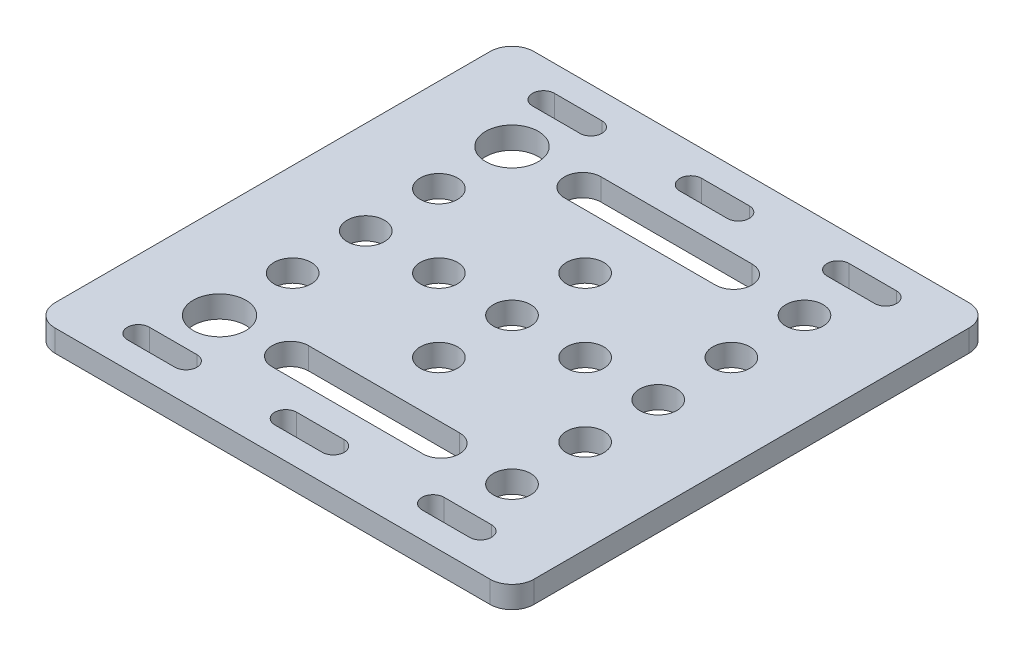
from build123d import *

# Parameters (mm, degrees)
SKETCH1_W           = 65.5
SKETCH1_H           = 65.5
BOSS_EXTRUDE1_DEPTH = 3
SKETCH2_R           = 3.6
SKETCH2_R_2         = 2.55
CUT_EXTRUDE1_DEPTH  = 4
FILLET1_R           = 3


with BuildPart() as part:
    # Sketch1 → Boss-Extrude1 (new body)
    with BuildSketch(Plane(origin=(0, 0, 0), x_dir=(1, 0, 0), z_dir=(0, 1, 0))):
        Rectangle(SKETCH1_W, SKETCH1_H)
    extrude(amount=BOSS_EXTRUDE1_DEPTH)

    # Sketch2 → Cut-Extrude1 (cut, through all)
    with BuildSketch(Plane(origin=(0, 3, 0), x_dir=(1, 0, 0), z_dir=(0, 1, 0))):
        with BuildLine():
            ThreePointArc((-23.4, 29.2), (-24.9, 27.7), (-23.4, 26.2))
            Line((-23.4, 26.2), (-23.4, 29.2))
        make_face()
        with BuildLine():
            Line((-23.4, 29.2), (-23.4, 26.2))
            ThreePointArc((-23.4, 26.2), (-22.339339828, 26.639339828), (-21.9, 27.7))
            ThreePointArc((-21.9, 27.7), (-22.339339828, 28.760660172), (-23.4, 29.2))
        make_face()
        with BuildLine():
            Line((-23.4, 26.2), (-16.9, 26.2))
            ThreePointArc((-16.9, 26.2), (-18.4, 27.7), (-16.9, 29.2))
            Line((-16.9, 29.2), (-23.4, 29.2))
            ThreePointArc((-23.4, 29.2), (-22.339339828, 28.760660172), (-21.9, 27.7))
            ThreePointArc((-21.9, 27.7), (-22.339339828, 26.639339828), (-23.4, 26.2))
        make_face()
        with BuildLine():
            ThreePointArc((-16.9, 29.2), (-18.4, 27.7), (-16.9, 26.2))
            Line((-16.9, 26.2), (-16.9, 29.2))
        make_face()
        with BuildLine():
            Line((-16.9, 29.2), (-16.9, 26.2))
            ThreePointArc((-16.9, 26.2), (-15.839339828, 26.639339828), (-15.4, 27.7))
            ThreePointArc((-15.4, 27.7), (-15.839339828, 28.760660172), (-16.9, 29.2))
        make_face()
        with BuildLine():
            ThreePointArc((-1.75, 27.7), (-2.189339828, 28.760660172), (-3.25, 29.2))
            Line((-3.25, 29.2), (-3.25, 26.2))
            ThreePointArc((-3.25, 26.2), (-2.189339828, 26.639339828), (-1.75, 27.7))
        make_face()
        with BuildLine():
            Line((-3.25, 26.2), (-3.25, 29.2))
            ThreePointArc((-3.25, 29.2), (-4.75, 27.7), (-3.25, 26.2))
        make_face()
        with BuildLine():
            ThreePointArc((3.25, 26.2), (1.75, 27.7), (3.25, 29.2))
            Line((3.25, 29.2), (-3.25, 29.2))
            ThreePointArc((-3.25, 29.2), (-2.189339828, 28.760660172), (-1.75, 27.7))
            ThreePointArc((-1.75, 27.7), (-2.189339828, 26.639339828), (-3.25, 26.2))
            Line((-3.25, 26.2), (3.25, 26.2))
        make_face()
        with BuildLine():
            ThreePointArc((4.75, 27.7), (4.310660172, 28.760660172), (3.25, 29.2))
            Line((3.25, 29.2), (3.25, 26.2))
            ThreePointArc((3.25, 26.2), (4.310660172, 26.639339828), (4.75, 27.7))
        make_face()
        with BuildLine():
            Line((3.25, 26.2), (3.25, 29.2))
            ThreePointArc((3.25, 29.2), (1.75, 27.7), (3.25, 26.2))
        make_face()
        with BuildLine():
            ThreePointArc((18.4, 27.7), (17.960660172, 28.760660172), (16.9, 29.2))
            Line((16.9, 29.2), (16.9, 26.2))
            ThreePointArc((16.9, 26.2), (17.960660172, 26.639339828), (18.4, 27.7))
        make_face()
        with BuildLine():
            Line((16.9, 26.2), (16.9, 29.2))
            ThreePointArc((16.9, 29.2), (15.4, 27.7), (16.9, 26.2))
        make_face()
        with BuildLine():
            ThreePointArc((23.4, 26.2), (21.9, 27.7), (23.4, 29.2))
            Line((23.4, 29.2), (16.9, 29.2))
            ThreePointArc((16.9, 29.2), (17.960660172, 28.760660172), (18.4, 27.7))
            ThreePointArc((18.4, 27.7), (17.960660172, 26.639339828), (16.9, 26.2))
            Line((16.9, 26.2), (23.4, 26.2))
        make_face()
        with BuildLine():
            ThreePointArc((24.9, 27.7), (24.460660172, 28.760660172), (23.4, 29.2))
            Line((23.4, 29.2), (23.4, 26.2))
            ThreePointArc((23.4, 26.2), (24.460660172, 26.639339828), (24.9, 27.7))
        make_face()
        with BuildLine():
            Line((23.4, 26.2), (23.4, 29.2))
            ThreePointArc((23.4, 29.2), (21.9, 27.7), (23.4, 26.2))
        make_face()
        with Locations((-20, 20)):
            Circle(SKETCH2_R)
        with BuildLine():
            ThreePointArc((-10.32, 22.5), (-12.82, 20), (-10.32, 17.5))
            Line((-10.32, 17.5), (-10.32, 22.5))
        make_face()
        with BuildLine():
            Line((-10.32, 22.5), (-10.32, 17.5))
            ThreePointArc((-10.32, 17.5), (-8.552233047, 18.232233047), (-7.82, 20))
            ThreePointArc((-7.82, 20), (-8.552233047, 21.767766953), (-10.32, 22.5))
        make_face()
        with BuildLine():
            Line((-10.32, 17.5), (10.32, 17.5))
            ThreePointArc((10.32, 17.5), (7.82, 20), (10.32, 22.5))
            Line((10.32, 22.5), (-10.32, 22.5))
            ThreePointArc((-10.32, 22.5), (-8.552233047, 21.767766953), (-7.82, 20))
            ThreePointArc((-7.82, 20), (-8.552233047, 18.232233047), (-10.32, 17.5))
        make_face()
        with BuildLine():
            ThreePointArc((10.32, 22.5), (7.82, 20), (10.32, 17.5))
            Line((10.32, 17.5), (10.32, 22.5))
        make_face()
        with BuildLine():
            Line((10.32, 22.5), (10.32, 17.5))
            ThreePointArc((10.32, 17.5), (12.087766953, 18.232233047), (12.82, 20))
            ThreePointArc((12.82, 20), (12.087766953, 21.767766953), (10.32, 22.5))
        make_face()
        with Locations((20, 20)):
            Circle(SKETCH2_R_2)
        with Locations((-20, 10)):
            Circle(SKETCH2_R_2)
        with Locations((0, 10)):
            Circle(SKETCH2_R_2)
        with Locations((20, 10)):
            Circle(SKETCH2_R_2)
        with Locations((-20, 0)):
            Circle(SKETCH2_R_2)
        with Locations((-10, 0)):
            Circle(SKETCH2_R_2)
        Circle(SKETCH2_R_2)
        with Locations((10, 0)):
            Circle(SKETCH2_R_2)
        with Locations((20, 0)):
            Circle(SKETCH2_R_2)
        with Locations((-20, -10)):
            Circle(SKETCH2_R_2)
        with Locations((0, -10)):
            Circle(SKETCH2_R_2)
        with Locations((20, -10)):
            Circle(SKETCH2_R_2)
        with Locations((-20, -20)):
            Circle(SKETCH2_R)
        with BuildLine():
            ThreePointArc((-7.82, -20), (-8.552233047, -18.232233047), (-10.32, -17.5))
            Line((-10.32, -17.5), (-10.32, -22.5))
            ThreePointArc((-10.32, -22.5), (-8.552233047, -21.767766953), (-7.82, -20))
        make_face()
        with BuildLine():
            Line((-10.32, -22.5), (-10.32, -17.5))
            ThreePointArc((-10.32, -17.5), (-12.82, -20), (-10.32, -22.5))
        make_face()
        with BuildLine():
            Line((0, -22.5), (0, -17.5))
            Line((0, -17.5), (-10.32, -17.5))
            ThreePointArc((-10.32, -17.5), (-8.552233047, -18.232233047), (-7.82, -20))
            ThreePointArc((-7.82, -20), (-8.552233047, -21.767766953), (-10.32, -22.5))
            Line((-10.32, -22.5), (0, -22.5))
        make_face()
        with BuildLine():
            ThreePointArc((10.32, -22.5), (7.82, -20), (10.32, -17.5))
            Line((10.32, -17.5), (0, -17.5))
            Line((0, -17.5), (0, -22.5))
            Line((0, -22.5), (10.32, -22.5))
        make_face()
        with BuildLine():
            ThreePointArc((12.82, -20), (12.087766953, -18.232233047), (10.32, -17.5))
            Line((10.32, -17.5), (10.32, -22.5))
            ThreePointArc((10.32, -22.5), (12.087766953, -21.767766953), (12.82, -20))
        make_face()
        with BuildLine():
            Line((10.32, -22.5), (10.32, -17.5))
            ThreePointArc((10.32, -17.5), (7.82, -20), (10.32, -22.5))
        make_face()
        with Locations((20, -20)):
            Circle(SKETCH2_R_2)
        with BuildLine():
            ThreePointArc((-23.4, -26.2), (-24.9, -27.7), (-23.4, -29.2))
            Line((-23.4, -29.2), (-23.4, -26.2))
        make_face()
        with BuildLine():
            Line((-23.4, -26.2), (-23.4, -29.2))
            ThreePointArc((-23.4, -29.2), (-22.339339828, -28.760660172), (-21.9, -27.7))
            ThreePointArc((-21.9, -27.7), (-22.339339828, -26.639339828), (-23.4, -26.2))
        make_face()
        with BuildLine():
            Line((-23.4, -29.2), (-16.9, -29.2))
            ThreePointArc((-16.9, -29.2), (-18.4, -27.7), (-16.9, -26.2))
            Line((-16.9, -26.2), (-23.4, -26.2))
            ThreePointArc((-23.4, -26.2), (-22.339339828, -26.639339828), (-21.9, -27.7))
            ThreePointArc((-21.9, -27.7), (-22.339339828, -28.760660172), (-23.4, -29.2))
        make_face()
        with BuildLine():
            ThreePointArc((-16.9, -26.2), (-18.4, -27.7), (-16.9, -29.2))
            Line((-16.9, -29.2), (-16.9, -26.2))
        make_face()
        with BuildLine():
            Line((-16.9, -26.2), (-16.9, -29.2))
            ThreePointArc((-16.9, -29.2), (-15.839339828, -28.760660172), (-15.4, -27.7))
            ThreePointArc((-15.4, -27.7), (-15.839339828, -26.639339828), (-16.9, -26.2))
        make_face()
        with BuildLine():
            ThreePointArc((-3.25, -26.2), (-4.75, -27.7), (-3.25, -29.2))
            Line((-3.25, -29.2), (-3.25, -26.2))
        make_face()
        with BuildLine():
            Line((-3.25, -26.2), (-3.25, -29.2))
            ThreePointArc((-3.25, -29.2), (-2.189339828, -28.760660172), (-1.75, -27.7))
            ThreePointArc((-1.75, -27.7), (-2.189339828, -26.639339828), (-3.25, -26.2))
        make_face()
        with BuildLine():
            Line((-3.25, -29.2), (3.25, -29.2))
            ThreePointArc((3.25, -29.2), (1.75, -27.7), (3.25, -26.2))
            Line((3.25, -26.2), (-3.25, -26.2))
            ThreePointArc((-3.25, -26.2), (-2.189339828, -26.639339828), (-1.75, -27.7))
            ThreePointArc((-1.75, -27.7), (-2.189339828, -28.760660172), (-3.25, -29.2))
        make_face()
        with BuildLine():
            ThreePointArc((3.25, -26.2), (1.75, -27.7), (3.25, -29.2))
            Line((3.25, -29.2), (3.25, -26.2))
        make_face()
        with BuildLine():
            Line((3.25, -26.2), (3.25, -29.2))
            ThreePointArc((3.25, -29.2), (4.310660172, -28.760660172), (4.75, -27.7))
            ThreePointArc((4.75, -27.7), (4.310660172, -26.639339828), (3.25, -26.2))
        make_face()
        with BuildLine():
            ThreePointArc((16.9, -26.2), (15.4, -27.7), (16.9, -29.2))
            Line((16.9, -29.2), (16.9, -26.2))
        make_face()
        with BuildLine():
            Line((16.9, -26.2), (16.9, -29.2))
            ThreePointArc((16.9, -29.2), (17.960660172, -28.760660172), (18.4, -27.7))
            ThreePointArc((18.4, -27.7), (17.960660172, -26.639339828), (16.9, -26.2))
        make_face()
        with BuildLine():
            Line((16.9, -29.2), (23.4, -29.2))
            ThreePointArc((23.4, -29.2), (21.9, -27.7), (23.4, -26.2))
            Line((23.4, -26.2), (16.9, -26.2))
            ThreePointArc((16.9, -26.2), (17.960660172, -26.639339828), (18.4, -27.7))
            ThreePointArc((18.4, -27.7), (17.960660172, -28.760660172), (16.9, -29.2))
        make_face()
        with BuildLine():
            ThreePointArc((23.4, -26.2), (21.9, -27.7), (23.4, -29.2))
            Line((23.4, -29.2), (23.4, -26.2))
        make_face()
        with BuildLine():
            Line((23.4, -26.2), (23.4, -29.2))
            ThreePointArc((23.4, -29.2), (24.460660172, -28.760660172), (24.9, -27.7))
            ThreePointArc((24.9, -27.7), (24.460660172, -26.639339828), (23.4, -26.2))
        make_face()
    extrude(amount=-CUT_EXTRUDE1_DEPTH, mode=Mode.SUBTRACT)

    # Fillet1
    fillet1_edges = [part.edges().sort_by_distance(p)[0] for p in [
        (-32.75, 1.5, -32.75),
        (32.75, 1.5, -32.75),
        (32.75, 1.5, 32.75),
        (-32.75, 1.5, 32.75),
    ]]
    fillet(fillet1_edges, radius=FILLET1_R)


solid = part.part
